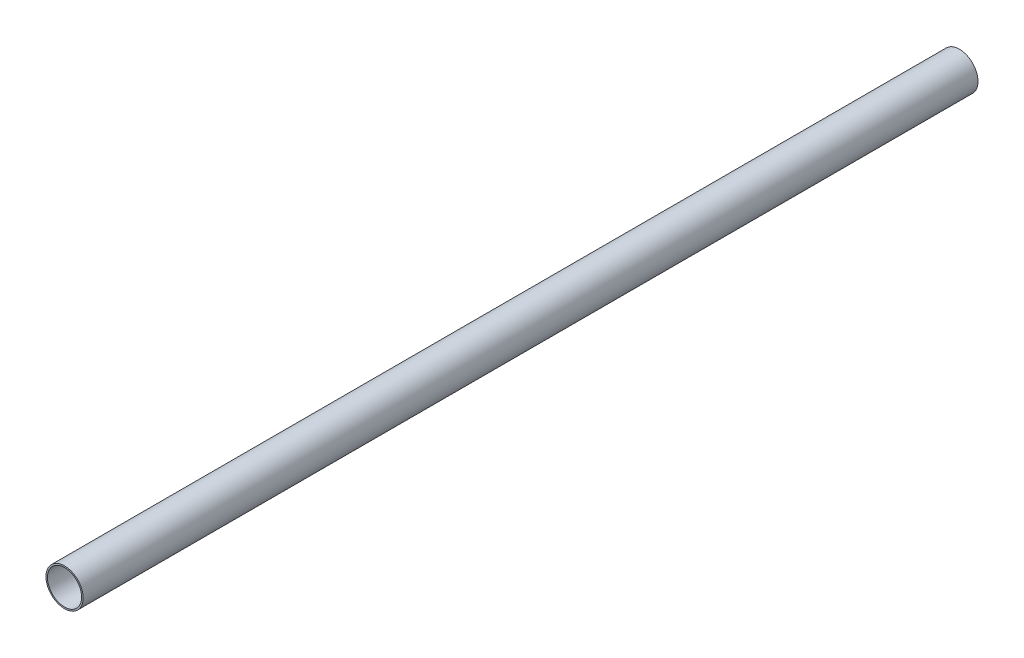
from build123d import *

# Parameters (mm, degrees)
SKETCH1_R           = 13.716
SKETCH1_R_2         = 12.6238
EXTRUDE_THIN1_DEPTH = 330.2


with BuildPart() as part:
    # Sketch1 → Extrude-Thin1 (new body, symmetric)
    with BuildSketch(Plane.XY):
        Circle(SKETCH1_R)
        Circle(SKETCH1_R_2, mode=Mode.SUBTRACT)
    extrude(amount=EXTRUDE_THIN1_DEPTH, both=True)


solid = part.part
